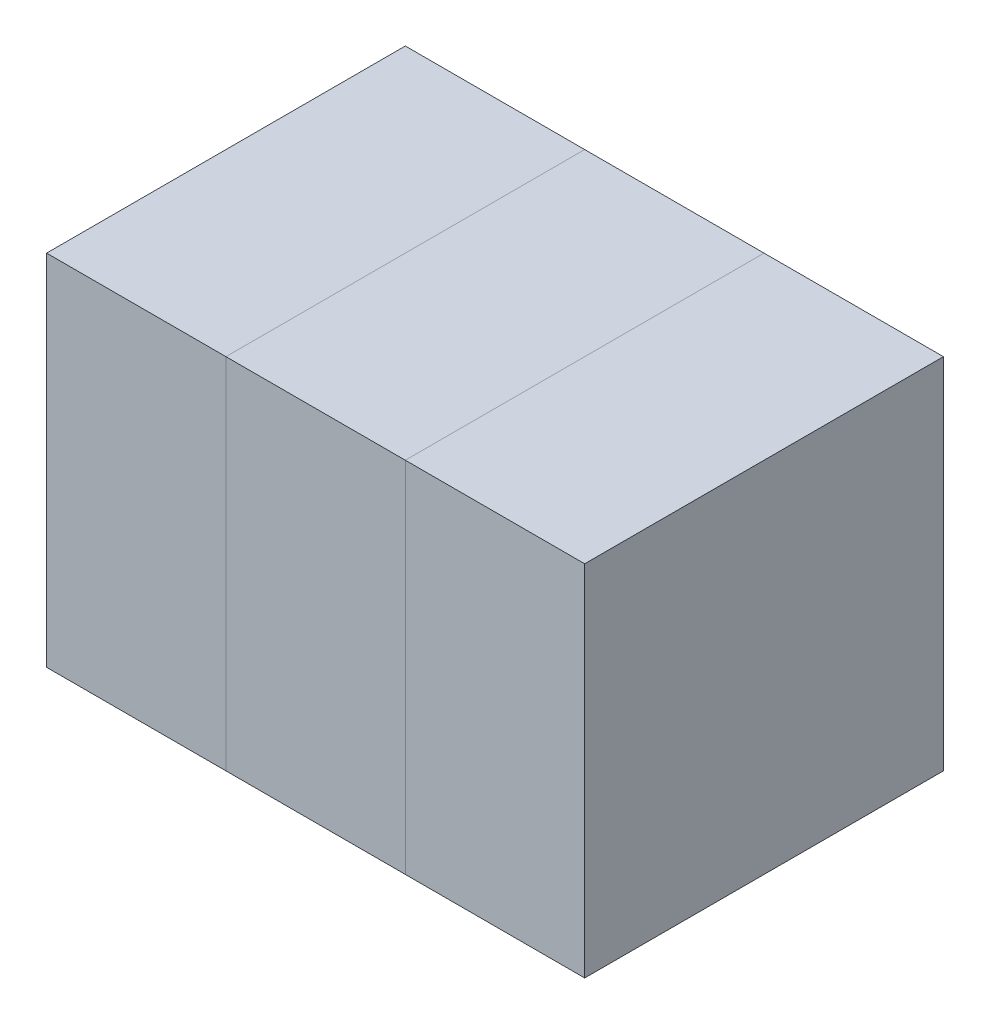
from build123d import *

# Parameters (mm, degrees)
SKETCH1_W             = 0.4
SKETCH1_H             = 0.8
BOSS_EXTRUDE1_DEPTH   = 0.8
SKETCH2_W             = 0.4
SKETCH2_H             = 0.8
BOSS_EXTRUDE2_DEPTH   = 0.8
BOSS_EXTRUDE2_2_DEPTH = 0.8


with BuildPart() as part:
    # Sketch1 → Boss-Extrude1 (new body)
    with BuildSketch(Plane(origin=(0, 0, 0), x_dir=(1, 0, 0), z_dir=(0, 1, 0))):
        Rectangle(SKETCH1_W, SKETCH1_H)
    extrude(amount=BOSS_EXTRUDE1_DEPTH)


with BuildPart() as body_2:
    # Sketch2 → Boss-Extrude2 (new body)
    with BuildSketch(Plane(origin=(0, 0, 0), x_dir=(1, 0, 0), z_dir=(0, 1, 0))):
        with Locations((-0.4, 0)):
            Rectangle(SKETCH2_W, SKETCH2_H)
    extrude(amount=BOSS_EXTRUDE2_DEPTH)


with BuildPart() as body_3:
    # Sketch2 → Boss-Extrude2 2 (new body)
    with BuildSketch(Plane(origin=(0, 0, 0), x_dir=(1, 0, 0), z_dir=(0, 1, 0))):
        with Locations((0.4, 0)):
            Rectangle(SKETCH2_W, SKETCH2_H)
    extrude(amount=BOSS_EXTRUDE2_2_DEPTH)


solid = Compound([part.part, body_2.part, body_3.part])
